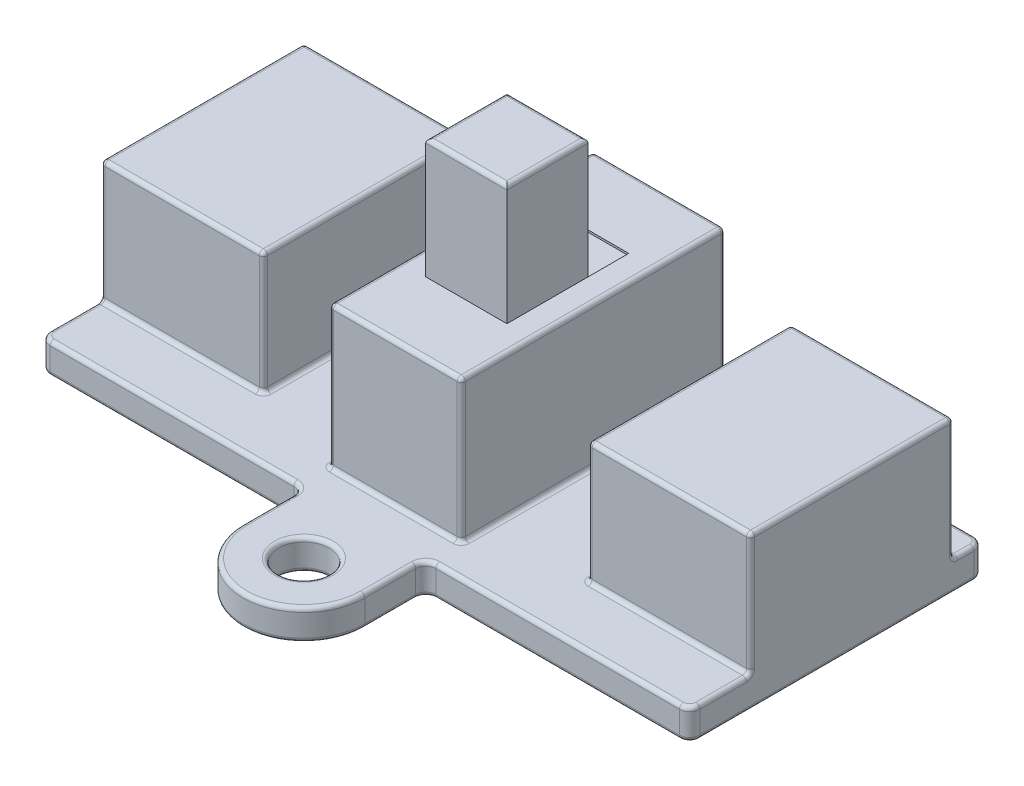
from build123d import *

# Parameters (mm, degrees)
SKETCH_1_R          = 1.25
PCB_DEPTH           = 1.5
SKETCH_2_W          = 8
SKETCH_2_H          = 10
EXTRUDE_1272_DEPTH  = 6
SKETCH_3_W          = 6.5
SKETCH_3_H          = 13
EXTRUDE_1607_DEPTH  = 7
SKETCH_4_W          = 4
SKETCH_4_H          = 6
CUT_EXTRUDE_1_DEPTH = 0.1
SKETCH_5_W          = 4
SKETCH_5_H          = 4
EXTRUDE_2037_DEPTH  = 6
FILLET_1_R          = 0.5
FILLET_2_R          = 0.2


with BuildPart() as part:
    # 草图1 → 凸台-拉伸-PCB板 (new body)
    with BuildSketch(Plane(origin=(0, 0, 0), x_dir=(1, 0, 0), z_dir=(0, 1, 0))):
        with BuildLine():
            ThreePointArc((-3, 0), (0, -3), (3, 0))
            Line((3, 0), (3, 3))
            Line((3, 3), (16, 3))
            Line((16, 3), (16, 17.5))
            Line((16, 17.5), (-16, 17.5))
            Line((-16, 17.5), (-16, 3))
            Line((-16, 3), (-3, 3))
            Line((-3, 3), (-3, 0))
        make_face()
        Circle(SKETCH_1_R, mode=Mode.SUBTRACT)
    extrude(amount=PCB_DEPTH)

    # 草图2 → Extrude 1272 (add)
    with BuildSketch(Plane(origin=(0, 1.5, 0), x_dir=(1, 0, 0), z_dir=(0, 1, 0))):
        with Locations((-12, 11)):
            Rectangle(SKETCH_2_W, SKETCH_2_H)
        with Locations((12, 11)):
            Rectangle(SKETCH_2_W, SKETCH_2_H)
    extrude(amount=EXTRUDE_1272_DEPTH)

    # 草图3 → Extrude 1607 (add)
    with BuildSketch(Plane(origin=(0, 1.5, 0), x_dir=(1, 0, 0), z_dir=(0, 1, 0))):
        with Locations((0, 11)):
            Rectangle(SKETCH_3_W, SKETCH_3_H)
    extrude(amount=EXTRUDE_1607_DEPTH)

    # 草图4 → 切除-拉伸1 (cut)
    with BuildSketch(Plane(origin=(0, 8.5, 0), x_dir=(1, 0, 0), z_dir=(0, 1, 0))):
        with Locations((0, 11)):
            Rectangle(SKETCH_4_W, SKETCH_4_H)
    extrude(amount=-CUT_EXTRUDE_1_DEPTH, mode=Mode.SUBTRACT)

    # 草图5 → Extrude 2037 (add)
    with BuildSketch(Plane(origin=(0, 8.4, 0), x_dir=(1, 0, 0), z_dir=(0, 1, 0))):
        with Locations((0, 10)):
            Rectangle(SKETCH_5_W, SKETCH_5_H)
    extrude(amount=EXTRUDE_2037_DEPTH)

    # 圆角1
    fillet_1_edges = [part.edges().sort_by_distance(p)[0] for p in [
        (-16, 0.75, -17.5),
        (-3, 0.75, -3),
        (-16, 0.75, -3),
        (3, 0.75, -3),
        (16, 0.75, -17.5),
        (16, 0.75, -3),
    ]]
    fillet(fillet_1_edges, radius=FILLET_1_R)

    # 圆角2
    fillet_2_edges = [part.edges().sort_by_distance(p)[0] for p in [
        (-3.25, 5, -17.5),
        (3.25, 5, -17.5),
        (16, 4.5, -16),
        (16, 4.5, -6),
        (-16, 4.5, -6),
        (-16, 4.5, -16),
        (0, 14.4, -12),
        (2, 14.4, -10),
        (0, 14.4, -8),
        (-2, 14.4, -10),
        (8, 4.5, -16),
        (8, 4.5, -6),
        (-8, 4.5, -6),
        (-8, 4.5, -16),
        (-3.25, 5, -4.5),
        (0, 8.5, -4.5),
        (3.25, 5, -4.5),
        (12, 7.5, -6),
        (8, 7.5, -11),
        (12, 7.5, -16),
        (16, 7.5, -11),
        (-12, 7.5, -16),
        (-8, 7.5, -11),
        (-12, 7.5, -6),
        (-16, 7.5, -11),
        (-3.25, 1.5, -11),
        (0, 1.5, -4.5),
        (3.25, 1.5, -11),
        (9.375, 1.5, -17.5),
        (15.853553391, 1.5, -17.353553391),
        (16, 1.5, -16.5),
        (12, 1.5, -16),
        (8, 1.5, -11),
        (12, 1.5, -6),
        (16, 1.5, -4.75),
        (15.853553391, 1.5, -3.146446609),
        (9.5, 1.5, -3),
        (3.146446609, 1.5, -2.853553391),
        (3, 1.5, -1.25),
        (0, 1.5, 3),
        (-3, 1.5, -1.25),
        (-3.146446609, 1.5, -2.853553391),
        (-9.5, 1.5, -3),
        (-15.853553391, 1.5, -3.146446609),
        (-16, 1.5, -4.75),
        (-12, 1.5, -6),
        (-8, 1.5, -11),
        (-12, 1.5, -16),
        (-16, 1.5, -16.5),
        (-15.853553391, 1.5, -17.353553391),
        (-9.375, 1.5, -17.5),
        (-1.25, 1.5, 0),
        (-1.25, 0, 0),
        (-15.853553391, 0, -3.146446609),
        (-9.5, 0, -3),
        (-3.146446609, 0, -2.853553391),
        (-3, 0, -1.25),
        (0, 0, 3),
        (3, 0, -1.25),
        (3.146446609, 0, -2.853553391),
        (9.5, 0, -3),
        (15.853553391, 0, -3.146446609),
        (16, 0, -10.25),
        (15.853553391, 0, -17.353553391),
        (0, 0, -17.5),
        (-15.853553391, 0, -17.353553391),
        (-16, 0, -10.25),
        (0, 8.5, -17.5),
        (-3.25, 8.5, -11),
        (3.25, 8.5, -11),
    ]]
    fillet(fillet_2_edges, radius=FILLET_2_R)


solid = part.part
